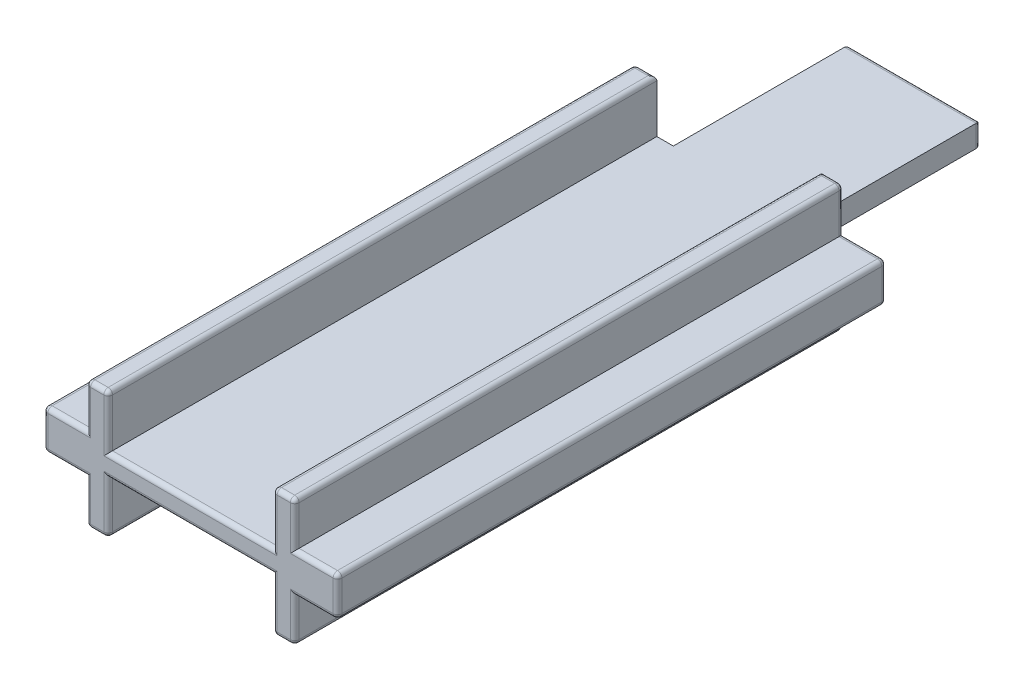
from build123d import *

# Parameters (mm, degrees)
AUFSATZ_LINEAR_AUSTRAGEN1_DEPTH = 25
SKIZZE2_W                       = 6
SKIZZE2_H                       = 1.8
AUFSATZ_LINEAR_AUSTRAGEN2_DEPTH = 8
SKIZZE3_W                       = 7.5
SKIZZE3_H                       = 0.4
SCHNITT_LINEAR_AUSTRAGEN1_DEPTH = 34
VERRUNDUNG1_R                   = 0.2


with BuildPart() as part:
    # Skizze1 → Aufsatz-Linear austragen1 (new body)
    with BuildSketch(Plane.XY):
        Polygon((-4.75, 0.9), (-6.7, 0.9), (-6.7, -0.9), (-4.75, -0.9), (-4.75, -2.9), (-3.75, -2.9), (-3.75, -0.9), (3.75, -0.9), (3.75, -2.9), (4.75, -2.9), (4.75, -0.9), (6.7, -0.9), (6.7, 0.9), (4.75, 0.9), (4.75, 2.9), (3.75, 2.9), (3.75, 0.9), (-3.75, 0.9), (-3.75, 2.9), (-4.75, 2.9), align=None)
    extrude(amount=AUFSATZ_LINEAR_AUSTRAGEN1_DEPTH)

    # Skizze2 → Aufsatz-Linear austragen2 (add)
    with BuildSketch(Plane(origin=(0, 0, 0), x_dir=(-1, 0, 0), z_dir=(0, 0, -1))):
        Rectangle(SKIZZE2_W, SKIZZE2_H)
    extrude(amount=AUFSATZ_LINEAR_AUSTRAGEN2_DEPTH)

    # Skizze3 → Schnitt-Linear austragen1 (cut, through all)
    with BuildSketch(Plane.XY.offset(25)):
        with Locations((0, -0.7)):
            Rectangle(SKIZZE3_W, SKIZZE3_H)
        with Locations((0, 0.7)):
            Rectangle(SKIZZE3_W, SKIZZE3_H)
    extrude(amount=-SCHNITT_LINEAR_AUSTRAGEN1_DEPTH, mode=Mode.SUBTRACT)

    # Verrundung1
    verrundung1_edges = [part.edges().sort_by_distance(p)[0] for p in [
        (0, 0.5, 25),
        (-4.75, -1.9, 25),
        (-4.25, -2.9, 25),
        (-5.725, 0.9, 0),
        (-4.75, 1.9, 0),
        (-4.25, 2.9, 0),
        (-3.75, -1.7, 25),
        (4.25, 2.9, 0),
        (4.75, 1.9, 0),
        (5.725, 0.9, 0),
        (6.7, 0, 0),
        (5.725, -0.9, 0),
        (4.75, -1.9, 0),
        (4.25, -2.9, 0),
        (-4.25, -2.9, 0),
        (-4.75, -1.9, 0),
        (-5.725, -0.9, 0),
        (-6.7, 0, 0),
        (3.75, -1.7, 25),
        (4.25, -2.9, 25),
        (-6.7, 0.9, 12.5),
        (-4.75, 2.9, 12.5),
        (-3.75, 2.9, 12.5),
        (3.75, 2.9, 12.5),
        (4.75, 2.9, 12.5),
        (6.7, 0.9, 12.5),
        (6.7, -0.9, 12.5),
        (4.75, -2.9, 12.5),
        (3.75, -2.9, 12.5),
        (-3.75, -2.9, 12.5),
        (-4.75, -2.9, 12.5),
        (-6.7, -0.9, 12.5),
        (4.75, -1.9, 25),
        (5.725, -0.9, 25),
        (6.7, 0, 25),
        (5.725, 0.9, 25),
        (-6.7, 0, 25),
        (4.75, 1.9, 25),
        (4.25, 2.9, 25),
        (3.75, 1.7, 25),
        (-3.75, 1.7, 25),
        (3, 0, -8),
        (-3, 0, -8),
        (-4.25, 2.9, 25),
        (0, 0.5, -8),
        (0, -0.5, -8),
        (-4.75, 1.9, 25),
        (-5.725, 0.9, 25),
        (0, -0.5, 25),
        (-5.725, -0.9, 25),
    ]]
    fillet(verrundung1_edges, radius=VERRUNDUNG1_R)


solid = part.part
